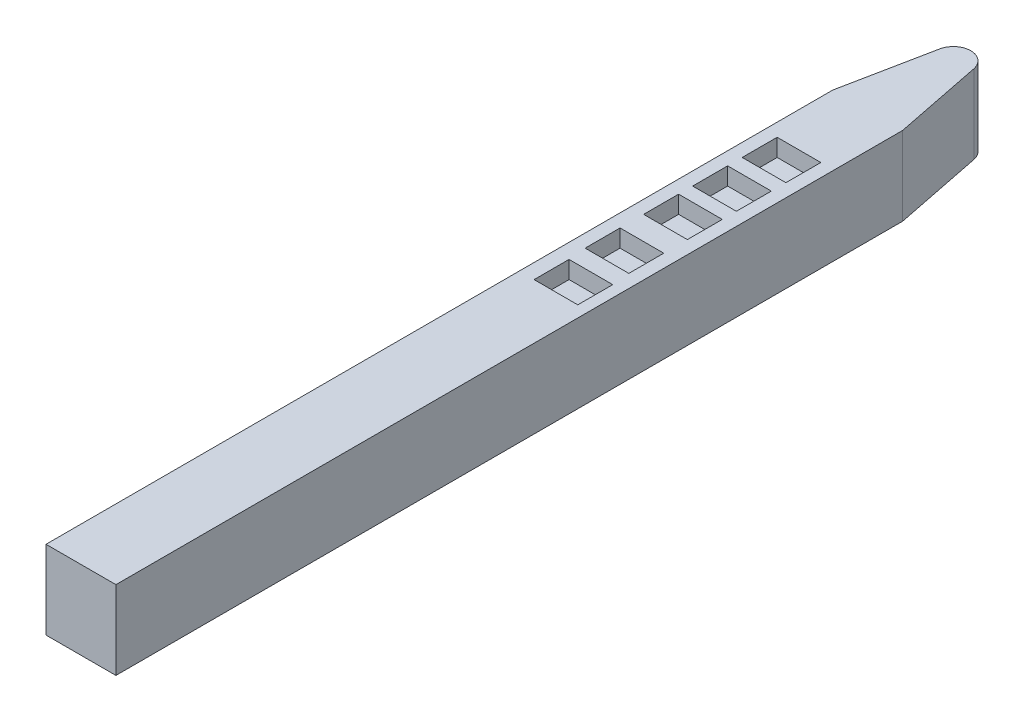
from build123d import *

# Parameters (mm, degrees)
BOSS_EXTRUDE1_DEPTH = 114.3
FILLET2_R           = 25.4
SKETCH2_W           = 63.5
SKETCH2_H           = 50.8
CUT_EXTRUDE1_DEPTH  = 25.4


with BuildPart() as part:
    # Sketch1 → Boss-Extrude1 (new body)
    with BuildSketch(Plane(origin=(0, 0, 0), x_dir=(1, 0, 0), z_dir=(0, 1, 0))):
        Polygon((0, 0), (0, 1143.361543418), (50.8, 1397), (101.6, 1143.361543418), (101.6, 0), align=None)
    extrude(amount=BOSS_EXTRUDE1_DEPTH)

    # Fillet2
    fillet2_edges = [part.edges().sort_by_distance(p)[0] for p in [
        (50.8, 57.15, -1397),
    ]]
    fillet(fillet2_edges, radius=FILLET2_R)

    # Sketch2 → Cut-Extrude1 (cut)
    with BuildSketch(Plane(origin=(0, 114.3, 0), x_dir=(1, 0, 0), z_dir=(0, 1, 0))):
        with Locations((50.8, 946.074302167)):
            Rectangle(SKETCH2_W, SKETCH2_H)
        with Locations((50.8, 1018.046396499)):
            Rectangle(SKETCH2_W, SKETCH2_H)
        with Locations((50.8, 874.822900853)):
            Rectangle(SKETCH2_W, SKETCH2_H)
        with Locations((50.8, 789.781020197)):
            Rectangle(SKETCH2_W, SKETCH2_H)
        with Locations((53.306135385, 713.133095909)):
            Rectangle(SKETCH2_W, SKETCH2_H)
    extrude(amount=-CUT_EXTRUDE1_DEPTH, mode=Mode.SUBTRACT)


solid = part.part
